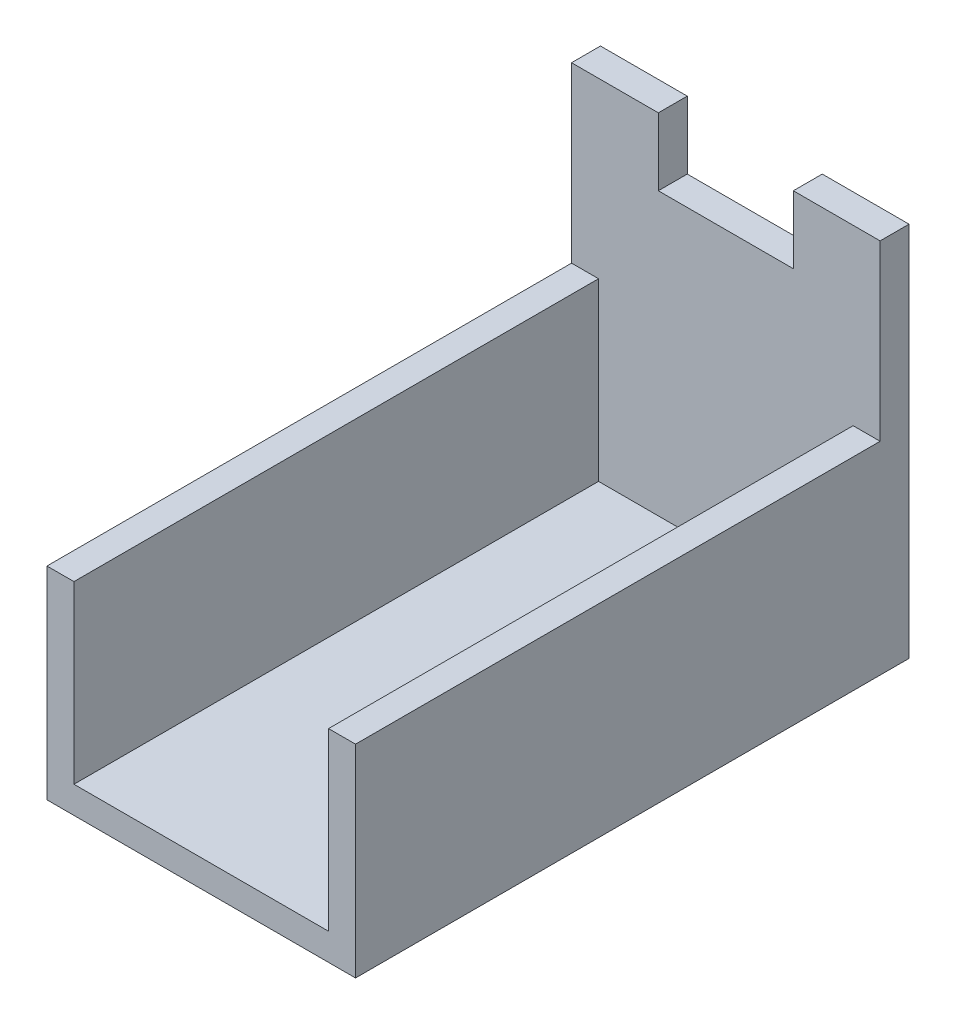
from build123d import *

# Parameters (mm, degrees)
BOSS_EXTRUDE1_DEPTH = 36.449
SKETCH3_W           = 16.764
SKETCH3_H           = 1.905
BOSS_EXTRUDE3_DEPTH = 11.557
BOSS_EXTRUDE4_DEPTH = 11.43
CUT_EXTRUDE1_REACH  = 38.449


with BuildPart() as part:
    # Sketch1 → Boss-Extrude1 (new body)
    with BuildSketch(Plane.XY):
        Polygon((-1.524, 1.692251565), (-1.524, 13.249251565), (0.254, 13.249251565), (0.254, -0.085748435), (-20.066, -0.085748435), (-20.066, 13.249251565), (-18.288, 13.249251565), (-18.288, 1.692251565), align=None)
    extrude(amount=-BOSS_EXTRUDE1_DEPTH)

    # Sketch3 → Boss-Extrude3 (add)
    with BuildSketch(Plane(origin=(0, 1.692251565, 0), x_dir=(1, 0, 0), z_dir=(0, 1, 0))):
        with Locations((-9.906, 35.4965)):
            Rectangle(SKETCH3_W, SKETCH3_H)
    extrude(amount=BOSS_EXTRUDE3_DEPTH)

    # Sketch4 → Boss-Extrude4 (add)
    with BuildSketch(Plane(origin=(0, 13.249251565, 0), x_dir=(1, 0, 0), z_dir=(0, 1, 0))):
        Polygon((-9.906, 34.544), (0.254, 34.544), (0.254, 36.449), (-20.066, 36.449), (-20.066, 34.544), align=None)
    extrude(amount=BOSS_EXTRUDE4_DEPTH)

    # Sketch5 → Cut-Extrude1 (cut, up to next)
    with BuildSketch(Plane(origin=(0, 0, -36.449), x_dir=(-1, 0, 0), z_dir=(0, 0, -1)), mode=Mode.PRIVATE) as cut_extrude1_sk1:
        Polygon((9.906, 24.679251565), (14.351, 24.679251565), (14.351, 20.234251565), (5.461, 20.234251565), (5.461, 24.679251565), align=None)
    cut_extrude1_tool1 = extrude(cut_extrude1_sk1.sketch, amount=-CUT_EXTRUDE1_REACH, mode=Mode.PRIVATE) & part.part
    add(cut_extrude1_tool1.solids().sort_by_distance((-9.906, 22.456752, -36.449))[0], mode=Mode.SUBTRACT)


solid = part.part
